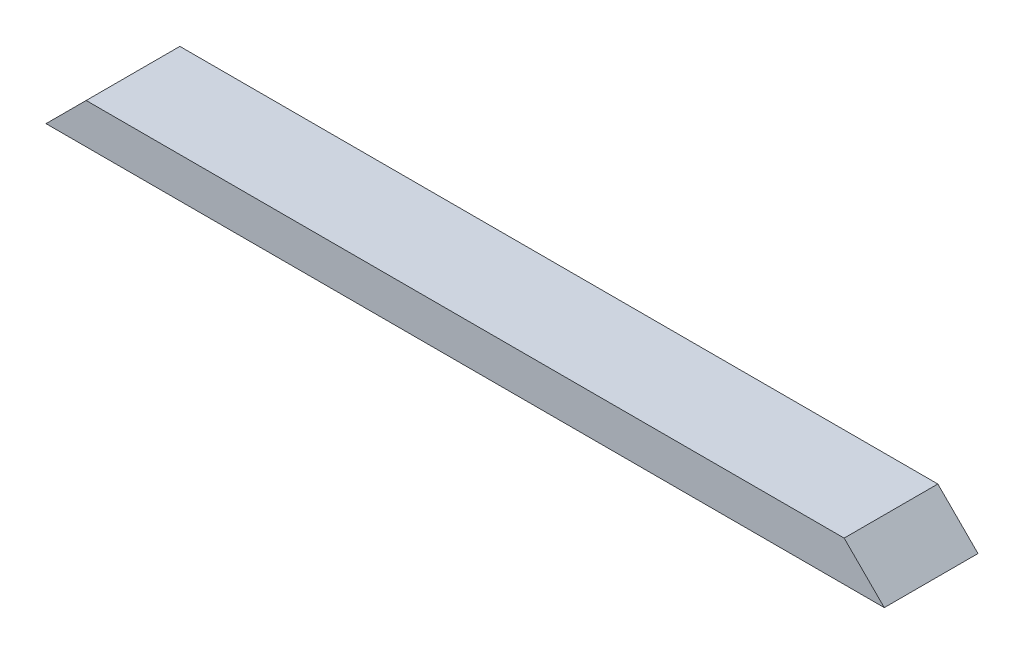
from build123d import *

# Parameters (mm, degrees)
SKETCH1_W           = 795.3756
SKETCH1_H           = 88.9
BOSS_EXTRUDE1_DEPTH = 38.1
CUT_EXTRUDE1_DEPTH  = 89.9


with BuildPart() as part:
    # Sketch1 → Boss-Extrude1 (new body)
    with BuildSketch(Plane(origin=(0, 0, 0), x_dir=(1, 0, 0), z_dir=(0, 1, 0))):
        with Locations((397.6878, 44.45)):
            Rectangle(SKETCH1_W, SKETCH1_H)
    extrude(amount=BOSS_EXTRUDE1_DEPTH)

    # Sketch2 → Cut-Extrude1 (cut, through all)
    with BuildSketch(Plane.XY):
        Polygon((0, 0), (38.1, 38.1), (0, 38.1), align=None)
        Polygon((795.3756, 0), (795.3756, 38.1), (757.2756, 38.1), align=None)
    extrude(amount=-CUT_EXTRUDE1_DEPTH, mode=Mode.SUBTRACT)


solid = part.part
